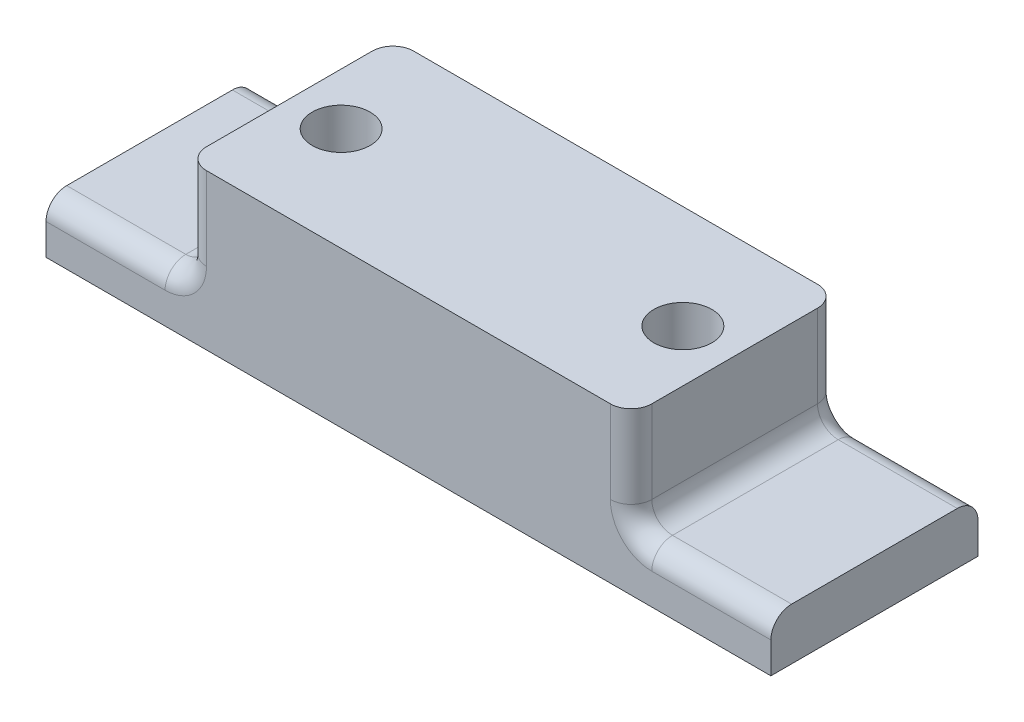
from build123d import *

# Parameters (mm, degrees)
SKETCH1_W           = 70
SKETCH1_H           = 20
BOSS_EXTRUDE1_DEPTH = 5
SKETCH2_W           = 43
SKETCH2_H           = 20
BOSS_EXTRUDE2_DEPTH = 10
FILLET1_R           = 2
SKETCH3_R           = 2.8
CUT_EXTRUDE1_DEPTH  = 16
CUT_EXTRUDE2_DEPTH  = 8


with BuildPart() as part:
    # Sketch1 → Boss-Extrude1 (new body)
    with BuildSketch(Plane(origin=(0, 0, 0), x_dir=(1, 0, 0), z_dir=(0, 1, 0))):
        with Locations((5.262356584, 6.187481613)):
            Rectangle(SKETCH1_W, SKETCH1_H)
    extrude(amount=BOSS_EXTRUDE1_DEPTH)

    # Sketch2 → Boss-Extrude2 (add)
    with BuildSketch(Plane(origin=(0, 5, 0), x_dir=(1, 0, 0), z_dir=(0, 1, 0))):
        with Locations((5.262356584, 6.187481613)):
            Rectangle(SKETCH2_W, SKETCH2_H)
    extrude(amount=BOSS_EXTRUDE2_DEPTH)

    # Fillet1
    fillet1_edges = [part.edges().sort_by_distance(p)[0] for p in [
        (-22.987643416, 5, 3.812518387),
        (-22.987643416, 5, -16.187481613),
        (33.512356584, 5, 3.812518387),
        (26.762356584, 5, -6.187481613),
        (26.762356584, 10, 3.812518387),
        (26.762356584, 10, -16.187481613),
        (-16.237643416, 5, -6.187481613),
        (-16.237643416, 10, -16.187481613),
        (-16.237643416, 10, 3.812518387),
        (33.512356584, 5, -16.187481613),
    ]]
    fillet(fillet1_edges, radius=FILLET1_R)

    # Sketch3 → Cut-Extrude1 (cut, through all)
    with BuildSketch(Plane(origin=(0, 15, 0), x_dir=(1, 0, 0), z_dir=(0, 1, 0))):
        with Locations((21.762356584, 6.187481613)):
            Circle(SKETCH3_R)
        with Locations((-11.237643416, 6.187481613)):
            Circle(SKETCH3_R)
    extrude(amount=-CUT_EXTRUDE1_DEPTH, mode=Mode.SUBTRACT)

    # Sketch4 → Cut-Extrude2 (cut)
    with BuildSketch(Plane.XZ):
        Polygon((-8.098072068, -9.959274965), (-6.401388882, -5.354429745), (-9.54096023, -1.582636394), (-14.377214764, -2.415688262), (-16.07389795, -7.020533482), (-12.934326602, -10.792326833), align=None)
        Polygon((23.45903977, -10.792326833), (18.622785236, -9.959274965), (16.92610205, -5.354429745), (20.065673398, -1.582636394), (24.901927932, -2.415688262), (26.598611118, -7.020533482), align=None)
    extrude(amount=-CUT_EXTRUDE2_DEPTH, mode=Mode.SUBTRACT)


solid = part.part
